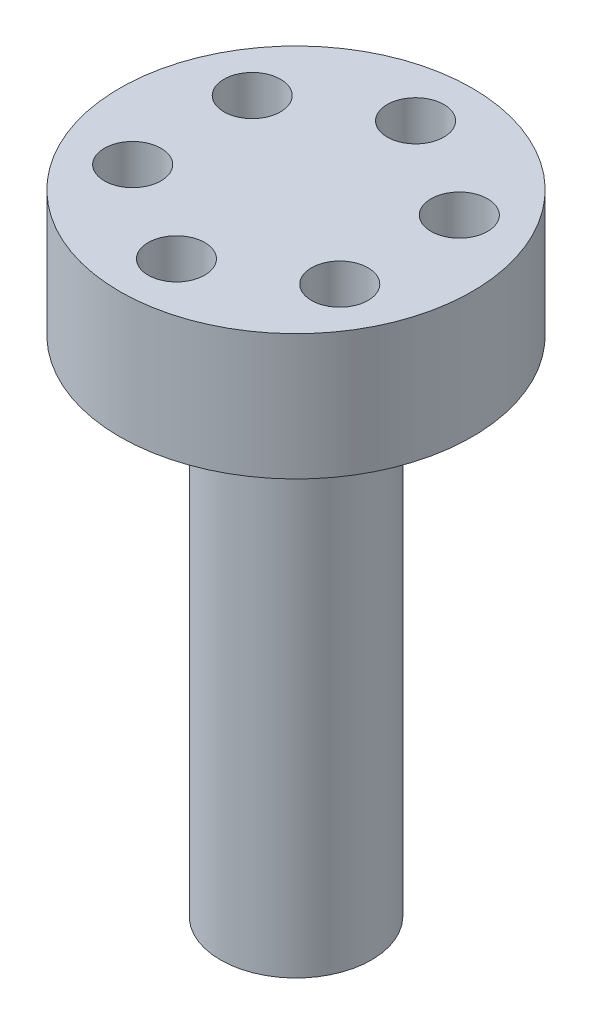
from build123d import *

# Parameters (mm, degrees)
SKETCH1_R           = 6
BOSS_EXTRUDE1_DEPTH = 20
SKETCH4_R           = 14
BOSS_EXTRUDE2_DEPTH = 10
SKETCH5_R           = 2.25
CUT_EXTRUDE2_DEPTH  = 10
CIRPATTERN1_COUNT   = 6
SKETCH7_R           = 1.75
CUT_EXTRUDE3_DEPTH  = 10
CIRPATTERN2_COUNT   = 3


with BuildPart() as part:
    # Sketch1 → Boss-Extrude1 (new body, symmetric)
    with BuildSketch(Plane(origin=(0, 0, 0), x_dir=(1, 0, 0), z_dir=(0, 1, 0))):
        Circle(SKETCH1_R)
    extrude(amount=BOSS_EXTRUDE1_DEPTH, both=True)

    # Sketch4 → Boss-Extrude2 (add)
    with BuildSketch(Plane(origin=(0, 20, 0), x_dir=(1, 0, 0), z_dir=(0, 1, 0))):
        Circle(SKETCH4_R)
    extrude(amount=BOSS_EXTRUDE2_DEPTH)

    # Sketch5 → Cut-Extrude2 (cut)
    with BuildSketch(Plane(origin=(0, 30, 0), x_dir=(1, 0, 0), z_dir=(0, 1, 0))):
        with Locations((0, 9.5)):
            Circle(SKETCH5_R)
    cut_extrude2 = extrude(amount=-CUT_EXTRUDE2_DEPTH, mode=Mode.SUBTRACT)

    # CirPattern1: Cut-Extrude2 ×6 about axis
    cirpattern1_axis = Axis((0, 0, 0), (0, 1, 0))
    for i in range(1, CIRPATTERN1_COUNT):
        add(cut_extrude2.rotate(cirpattern1_axis, i * 360 / CIRPATTERN1_COUNT), mode=Mode.SUBTRACT)

    # Sketch7 → Cut-Extrude3 (cut)
    with BuildSketch(Plane.XZ.offset(20)):
        with Locations((0, 3)):
            Circle(SKETCH7_R)
    cut_extrude3 = extrude(amount=-CUT_EXTRUDE3_DEPTH, mode=Mode.SUBTRACT)

    # CirPattern2: Cut-Extrude3 ×3 about axis
    cirpattern2_axis = Axis((0, 0, 0), (0, 1, 0))
    for i in range(1, CIRPATTERN2_COUNT):
        add(cut_extrude3.rotate(cirpattern2_axis, i * 360 / CIRPATTERN2_COUNT), mode=Mode.SUBTRACT)


solid = part.part
